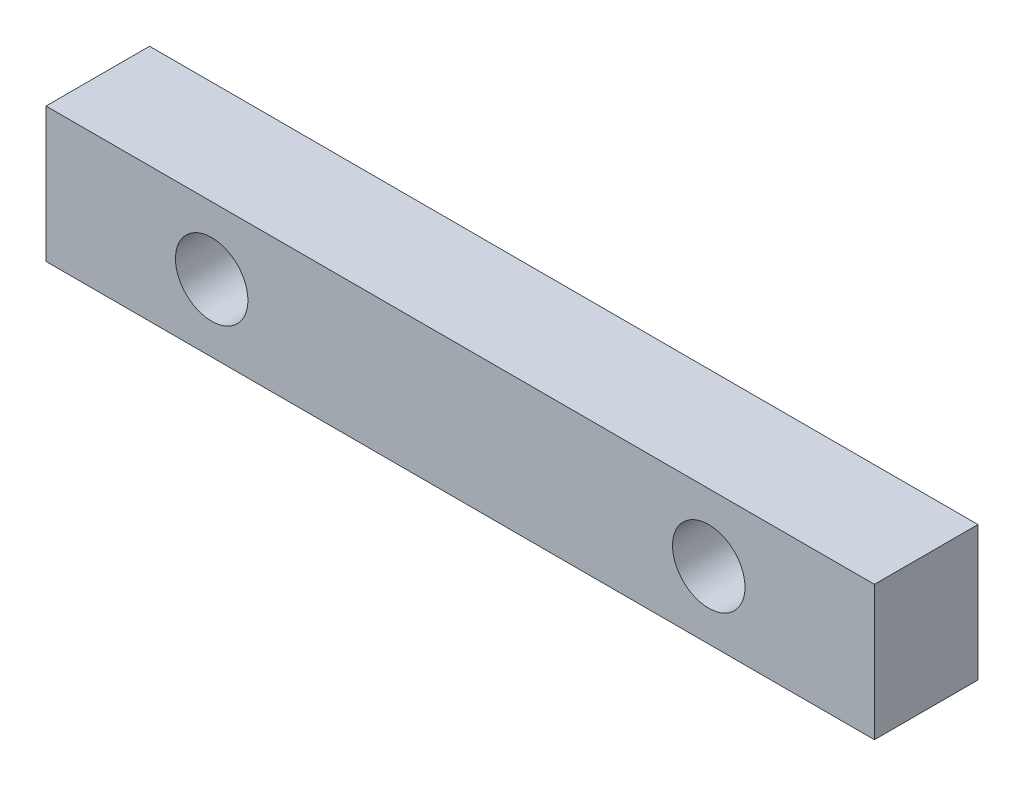
from build123d import *

# Parameters (mm, degrees)
SKETCH2_W           = 40
SKETCH2_H           = 6.5
SKETCH2_R           = 1.75
BOSS_EXTRUDE1_DEPTH = 5


with BuildPart() as part:
    # Sketch2 → Boss-Extrude1 (new body)
    with BuildSketch(Plane.XY):
        Rectangle(SKETCH2_W, SKETCH2_H)
        with Locations((-12, 0)):
            Circle(SKETCH2_R, mode=Mode.SUBTRACT)
        with Locations((12, 0)):
            Circle(SKETCH2_R, mode=Mode.SUBTRACT)
    extrude(amount=BOSS_EXTRUDE1_DEPTH)


solid = part.part
